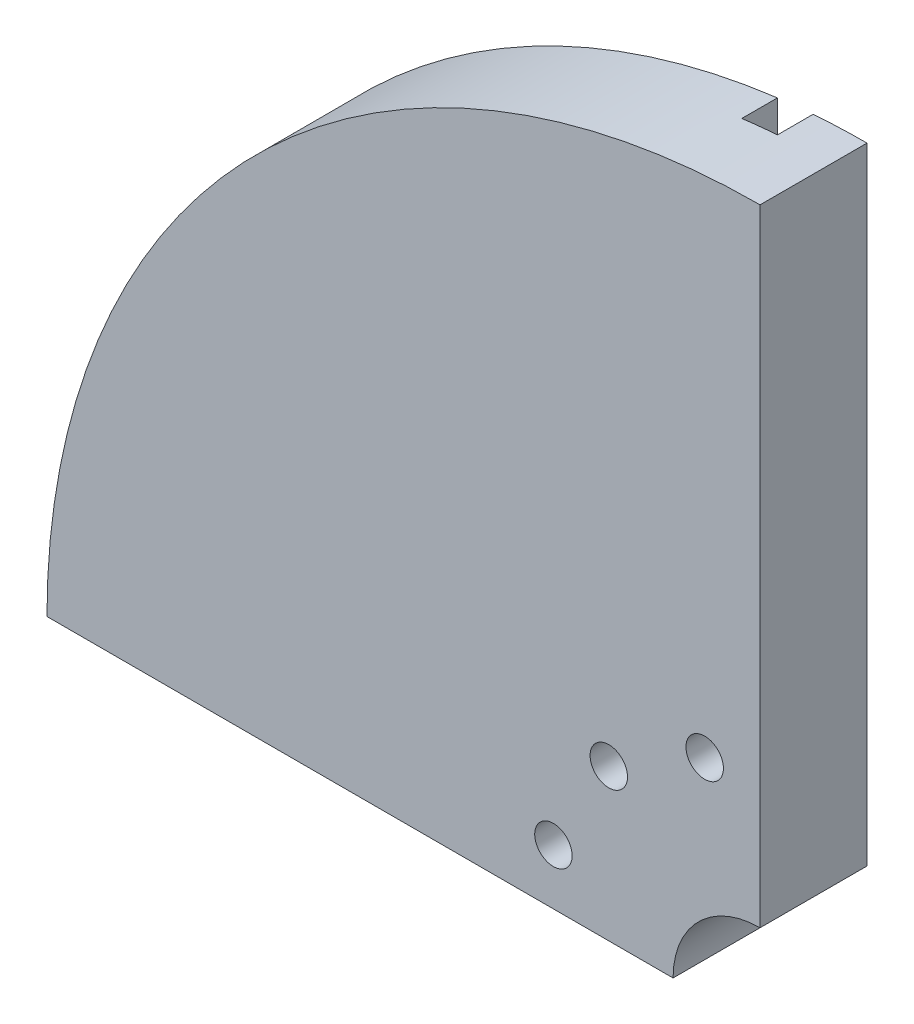
from build123d import *

# Parameters (mm, degrees)
BOSS_EXTRUDE1_DEPTH = 15
SKETCH2_R           = 2.625
CUT_EXTRUDE1_DEPTH  = 16
SKETCH3_R           = 12.2
CUT_EXTRUDE2_DEPTH  = 20
CUT_EXTRUDE5_DEPTH  = 10
SKETCH6_W           = 14
SKETCH6_H           = 20
SKETCH6_W_2         = 20
SKETCH6_H_2         = 14
CUT_EXTRUDE6_DEPTH  = 10
SKETCH8_W           = 10
SKETCH8_H           = 5
SKETCH8_W_2         = 5
SKETCH8_H_2         = 10
CUT_EXTRUDE7_DEPTH  = 5


with BuildPart() as part:
    # Sketch1 → Boss-Extrude1 (new body)
    with BuildSketch(Plane.XY):
        with BuildLine():
            Line((0, 100), (0, 0))
            Line((0, 0), (-100, 0))
            ThreePointArc((-100, 0), (-70.710678118, 70.710678118), (0, 100))
        make_face()
    extrude(amount=BOSS_EXTRUDE1_DEPTH)

    # Sketch2 → Cut-Extrude1 (cut, through all)
    with BuildSketch(Plane.XY):
        with Locations((-7.76457135, 28.97777479)):
            Circle(SKETCH2_R)
        with Locations((-21.213203434, 21.213203438)):
            Circle(SKETCH2_R)
        with Locations((-28.977774788, 7.764571356)):
            Circle(SKETCH2_R)
    extrude(amount=CUT_EXTRUDE1_DEPTH, mode=Mode.SUBTRACT)

    # Sketch3 → Cut-Extrude2 (cut)
    with BuildSketch(Plane.XY):
        Circle(SKETCH3_R)
    extrude(amount=CUT_EXTRUDE2_DEPTH, mode=Mode.SUBTRACT)

    # Sketch5 → Cut-Extrude5 (cut)
    with BuildSketch(Plane.XY):
        Polygon((-71.95873614, 20.826742868), (-61.115668074, 11.728328454), (-14.639983633, 67.115892355), (-25.483051698, 76.21430677), align=None)
        Polygon((-58.563247101, 10.460640314), (-47.720179035, 1.3622259), (-1.244494594, 56.749789802), (-12.087562659, 65.848204216), align=None)
        Polygon((-85.713169601, 31.896516461), (-74.870101536, 22.798102046), (-28.394417094, 78.185665948), (-39.237485159, 87.284080363), align=None)
    extrude(amount=CUT_EXTRUDE5_DEPTH, mode=Mode.SUBTRACT)

    # Sketch6 → Cut-Extrude6 (cut)
    with BuildSketch(Plane.XY):
        with Locations((-9.9593736, 84.419453757)):
            Rectangle(SKETCH6_W, SKETCH6_H)
        with Locations((-83.670510765, 9.900506549)):
            Rectangle(SKETCH6_W_2, SKETCH6_H_2)
    extrude(amount=CUT_EXTRUDE6_DEPTH, mode=Mode.SUBTRACT)

    # Sketch8 → Cut-Extrude7 (cut)
    with BuildSketch(Plane.XY):
        Polygon((-43.599799459, 8.831466661), (-89.403952996, 46.904961374), (-92.064810722, 42.671778628), (-46.260657185, 4.598283915), align=None)
        with Locations((-96.259669563, 9.424871496)):
            Rectangle(SKETCH8_W, SKETCH8_H)
        with Locations((-10.06190419, 97.056119442)):
            Rectangle(SKETCH8_W_2, SKETCH8_H_2)
    extrude(amount=CUT_EXTRUDE7_DEPTH, mode=Mode.SUBTRACT)


solid = part.part
